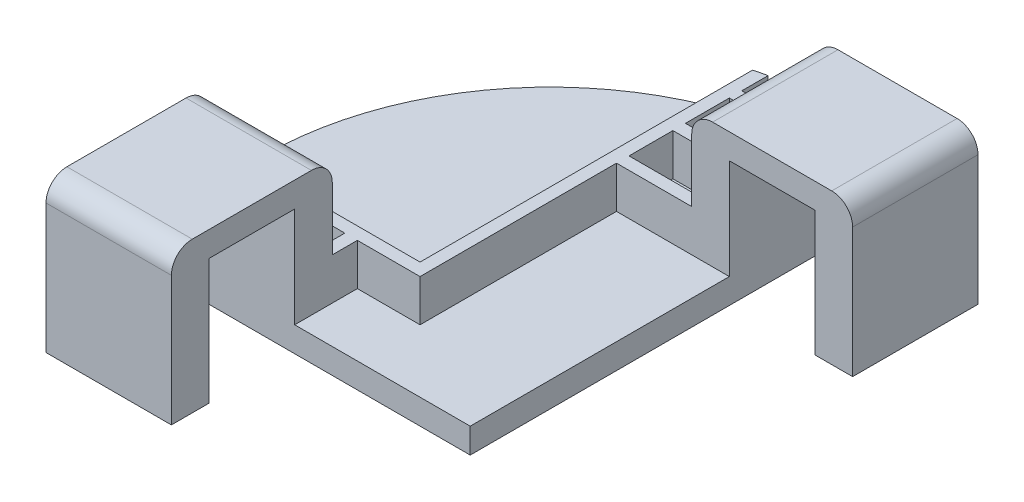
from build123d import *

# Parameters (mm, degrees)
SKETCH1_W           = 30
SKETCH1_H           = 9
SKETCH1_W_2         = 9
SKETCH1_H_2         = 30
BOSS_EXTRUDE1_DEPTH = 6
BOSS_EXTRUDE2_START = 6
SKETCH1_3_W         = 30
SKETCH1_3_H         = 9
SKETCH1_3_W_2       = 9
SKETCH1_3_H_2       = 30
BOSS_EXTRUDE2_DEPTH = 24
BOSS_EXTRUDE3_START = 30
SKETCH1_4_W         = 30
SKETCH1_4_H         = 9
SKETCH1_4_H_2       = 20.5
SKETCH1_4_W_2       = 9
SKETCH1_4_H_3       = 30
SKETCH1_4_W_3       = 20.5
BOSS_EXTRUDE3_DEPTH = 6
BOSS_EXTRUDE4_START = 30
SKETCH1_5_W         = 30
SKETCH1_5_H         = 9
SKETCH1_5_W_2       = 9
SKETCH1_5_H_2       = 30
BOSS_EXTRUDE4_DEPTH = 30
SKETCH2_W           = 3
SKETCH2_H           = 6
SKETCH2_W_2         = 18
SKETCH2_H_2         = 3
BOSS_EXTRUDE5_DEPTH = 10
FILLET1_R           = 5


with BuildPart() as part:
    # Sketch1 → Boss-Extrude1 (new body)
    with BuildSketch(Plane(origin=(0, 0, 0), x_dir=(1, 0, 0), z_dir=(0, 1, 0))):
        with Locations((-57, 4.5)):
            Rectangle(SKETCH1_W, SKETCH1_H)
        with Locations((-4.5, 77)):
            Rectangle(SKETCH1_W_2, SKETCH1_H_2)
        with BuildLine():
            Line((0, 99.896112213), (-12.24628833, 99.896112213))
            ThreePointArc((-12.24628833, 99.896112213), (-60.703064532, 79.824658322), (-80.774518424, 31.36788212))
            Line((-80.774518424, 31.36788212), (-80.774518424, 0))
            Line((-80.774518424, 0), (-72, 0))
            Line((-72, 0), (-72, 9))
            Line((-72, 9), (-42, 9))
            Line((-42, 9), (-42, 0))
            Line((-42, 0), (0, 0))
            Line((0, 0), (0, 62))
            Line((0, 62), (-9, 62))
            Line((-9, 62), (-9, 92))
            Line((-9, 92), (0, 92))
            Line((0, 92), (0, 99.896112213))
        make_face()
    extrude(amount=BOSS_EXTRUDE1_DEPTH)

    # Sketch1_3 → Boss-Extrude2 (add)
    with BuildSketch(Plane(origin=(0, 0, 0), x_dir=(1, 0, 0), z_dir=(0, 1, 0)).offset(BOSS_EXTRUDE2_START)):
        with Locations((-57, 4.5)):
            Rectangle(SKETCH1_3_W, SKETCH1_3_H)
        with Locations((-4.5, 77)):
            Rectangle(SKETCH1_3_W_2, SKETCH1_3_H_2)
    extrude(amount=BOSS_EXTRUDE2_DEPTH)

    # Sketch1_4 → Boss-Extrude3 (add)
    with BuildSketch(Plane(origin=(0, 0, 0), x_dir=(1, 0, 0), z_dir=(0, 1, 0)).offset(BOSS_EXTRUDE3_START)):
        with Locations((-57, 4.5)):
            Rectangle(SKETCH1_4_W, SKETCH1_4_H)
        with Locations((-57, -10.25)):
            Rectangle(SKETCH1_4_W, SKETCH1_4_H_2)
        with Locations((-57, -25)):
            Rectangle(SKETCH1_4_W, SKETCH1_4_H)
        with Locations((-4.5, 77)):
            Rectangle(SKETCH1_4_W_2, SKETCH1_4_H_3)
        with Locations((10.25, 77)):
            Rectangle(SKETCH1_4_W_3, SKETCH1_4_H_3)
        with Locations((25, 77)):
            Rectangle(SKETCH1_4_W_2, SKETCH1_4_H_3)
    extrude(amount=BOSS_EXTRUDE3_DEPTH)

    # Sketch1_5 → Boss-Extrude4 (add)
    with BuildSketch(Plane(origin=(0, 0, 0), x_dir=(1, 0, 0), z_dir=(0, 1, 0)).offset(BOSS_EXTRUDE4_START)):
        with Locations((-57, -25)):
            Rectangle(SKETCH1_5_W, SKETCH1_5_H)
        with Locations((25, 77)):
            Rectangle(SKETCH1_5_W_2, SKETCH1_5_H_2)
    extrude(amount=-BOSS_EXTRUDE4_DEPTH)

    # Sketch2 → Boss-Extrude5 (add)
    with BuildSketch(Plane(origin=(0, 6, 0), x_dir=(1, 0, 0), z_dir=(0, 1, 0))):
        with BuildLine():
            Line((-27, 89), (-27, 92))
            Line((-27, 92), (-27, 98.289076907))
            ThreePointArc((-27, 98.289076907), (-28.50412753, 97.9396553), (-30, 97.556431293))
            Line((-30, 97.556431293), (-30, 18))
            Line((-30, 18), (-80.774518424, 18))
            Line((-80.774518424, 18), (-80.774518424, 15))
            Line((-80.774518424, 15), (-72, 15))
            Line((-72, 15), (-69, 15))
            Line((-69, 15), (-58.5, 15))
            Line((-58.5, 15), (-55.5, 15))
            Line((-55.5, 15), (-45, 15))
            Line((-45, 15), (-42, 15))
            Line((-42, 15), (-27, 15))
            Line((-27, 15), (-27, 62))
            Line((-27, 62), (-27, 65))
            Line((-27, 65), (-27, 75.5))
            Line((-27, 75.5), (-27, 78.5))
            Line((-27, 78.5), (-27, 89))
        make_face()
        with Locations((-57, 12)):
            Rectangle(SKETCH2_W, SKETCH2_H)
        with Locations((-18, 77)):
            Rectangle(SKETCH2_W_2, SKETCH2_H_2)
        with Locations((-70.5, 12)):
            Rectangle(SKETCH2_W, SKETCH2_H)
        with Locations((-43.5, 12)):
            Rectangle(SKETCH2_W, SKETCH2_H)
        with Locations((-18, 63.5)):
            Rectangle(SKETCH2_W_2, SKETCH2_H_2)
        with Locations((-18, 90.5)):
            Rectangle(SKETCH2_W_2, SKETCH2_H_2)
    extrude(amount=BOSS_EXTRUDE5_DEPTH)

    # Fillet1
    fillet1_edges = [part.edges().sort_by_distance(p)[0] for p in [
        (-57, 36, -9),
        (-57, 36, 29.5),
        (29.5, 36, -77),
        (-9, 36, -77),
    ]]
    fillet(fillet1_edges, radius=FILLET1_R)


solid = part.part
